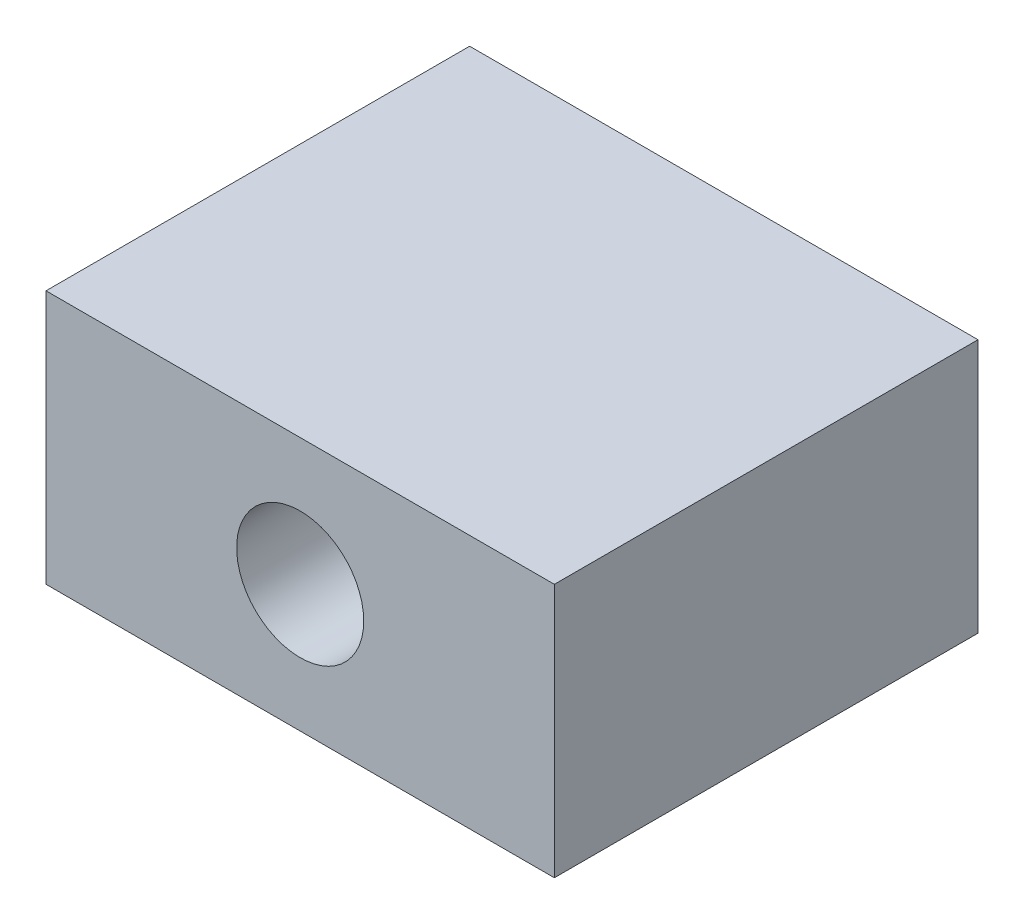
from build123d import *

# Parameters (mm, degrees)
SKETCH1_W           = 60
SKETCH1_H           = 30
SKETCH1_R           = 7.5
BOSS_EXTRUDE1_DEPTH = 25
SKETCH2_R           = 2.5
CUT_EXTRUDE1_DEPTH  = 30


with BuildPart() as part:
    # Sketch1 → Boss-Extrude1 (new body, symmetric)
    with BuildSketch(Plane.XY):
        with Locations((250, 0)):
            Rectangle(SKETCH1_W, SKETCH1_H)
        with Locations((250, 0)):
            Circle(SKETCH1_R, mode=Mode.SUBTRACT)
    extrude(amount=BOSS_EXTRUDE1_DEPTH, both=True)

    # Sketch2 → Cut-Extrude1 (cut)
    with BuildSketch(Plane.ZY.offset(-220)):
        with Locations((13.5, 0)):
            Circle(SKETCH2_R)
        with Locations((-13.5, 0)):
            Circle(SKETCH2_R)
    extrude(amount=-CUT_EXTRUDE1_DEPTH, mode=Mode.SUBTRACT)


solid = part.part
